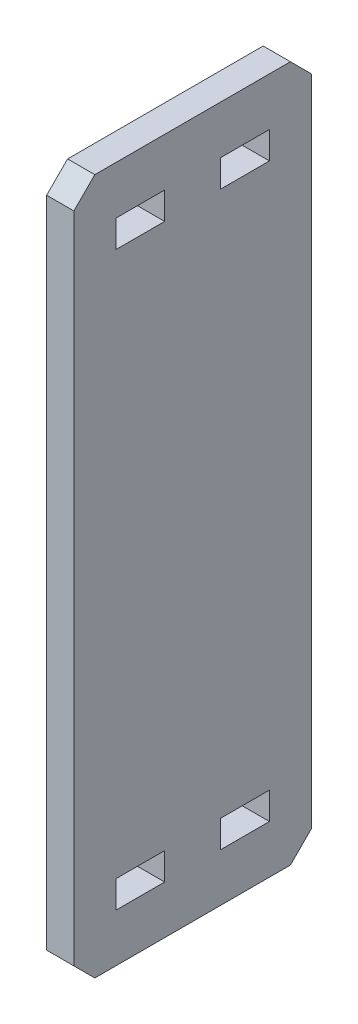
from build123d import *

# Parameters (mm, degrees)
SKETCH1_W           = 43.18
SKETCH1_H           = 126.492
SKETCH1_W_2         = 8.89
SKETCH1_H_2         = 4.953
BOSS_EXTRUDE1_DEPTH = 2.4765
CHAMFER1_SIZE       = 3.81


with BuildPart() as part:
    # Sketch1 → Boss-Extrude1 (new, symmetric)
    with BuildSketch(Plane(origin=(0, 0, 0), x_dir=(0, 0, -1), z_dir=(1, 0, 0))):
        with Locations((-111.027292876, 0)):
            Rectangle(SKETCH1_W, SKETCH1_H)
        with Locations((-101.502292876, 52.0065)):
            Rectangle(SKETCH1_W_2, SKETCH1_H_2, mode=Mode.SUBTRACT)
        with Locations((-120.552292876, 52.0065)):
            Rectangle(SKETCH1_W_2, SKETCH1_H_2, mode=Mode.SUBTRACT)
        with Locations((-101.502292876, -52.0065)):
            Rectangle(SKETCH1_W_2, SKETCH1_H_2, mode=Mode.SUBTRACT)
        with Locations((-120.552292876, -52.0065)):
            Rectangle(SKETCH1_W_2, SKETCH1_H_2, mode=Mode.SUBTRACT)
    extrude(amount=BOSS_EXTRUDE1_DEPTH, both=True)

    # Chamfer1
    chamfer1_edges = [part.edges().sort_by_distance(p)[0] for p in [
        (0, -63.246, 89.437292876),
        (0, -63.246, 132.617292876),
        (0, 63.246, 89.437292876),
        (0, 63.246, 132.617292876),
    ]]
    chamfer(chamfer1_edges, length=CHAMFER1_SIZE)


solid = part.part
